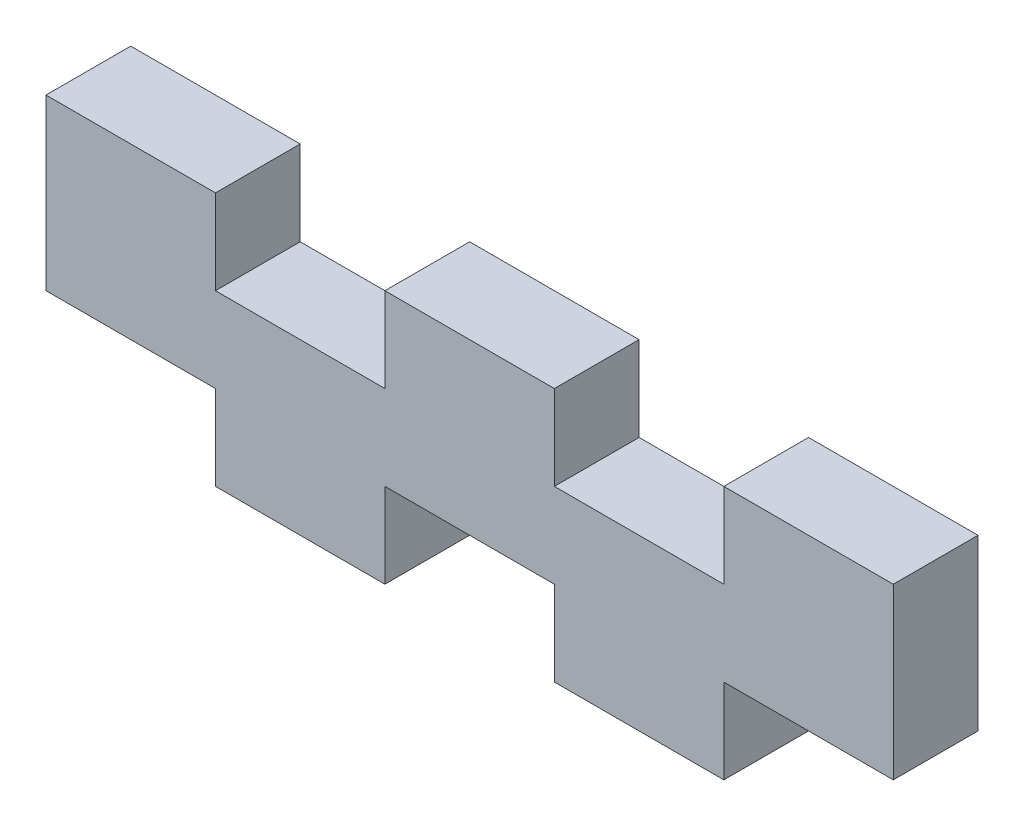
from build123d import *

# Parameters (mm, degrees)
SKETCH1_W           = 50.8
SKETCH1_H           = 15.24
BOSS_EXTRUDE1_DEPTH = 5.08
CUT_EXTRUDE2_REACH  = 7.08
SKETCH3_W           = 10.16
SKETCH3_H           = 5.08
CUT_EXTRUDE3_REACH  = 7.08
SKETCH4_W           = 10.16
SKETCH4_H           = 5.08


with BuildPart() as part:
    # Sketch1 → Boss-Extrude1 (new body)
    with BuildSketch(Plane.XY):
        with Locations((25.4, 7.62)):
            Rectangle(SKETCH1_W, SKETCH1_H)
    extrude(amount=BOSS_EXTRUDE1_DEPTH)

    # Sketch3 → Cut-Extrude2 (cut, up to next)
    with BuildSketch(Plane(origin=(0, 0, 0), x_dir=(-1, 0, 0), z_dir=(0, 0, -1)), mode=Mode.PRIVATE) as cut_extrude2_sk1:
        with Locations((-5.08, 2.54)):
            Rectangle(SKETCH3_W, SKETCH3_H)
    cut_extrude2_tool1 = extrude(cut_extrude2_sk1.sketch, amount=-CUT_EXTRUDE2_REACH, mode=Mode.PRIVATE) & part.part
    add(cut_extrude2_tool1.solids().sort_by_distance((5.08, 2.54, 0))[0], mode=Mode.SUBTRACT)
    # Sketch3 → Cut-Extrude2 (cut, up to next)
    with BuildSketch(Plane(origin=(0, 0, 0), x_dir=(-1, 0, 0), z_dir=(0, 0, -1)), mode=Mode.PRIVATE) as cut_extrude2_sk2:
        with Locations((-25.4, 2.54)):
            Rectangle(SKETCH3_W, SKETCH3_H)
    cut_extrude2_tool2 = extrude(cut_extrude2_sk2.sketch, amount=-CUT_EXTRUDE2_REACH, mode=Mode.PRIVATE) & part.part
    add(cut_extrude2_tool2.solids().sort_by_distance((25.4, 2.54, 0))[0], mode=Mode.SUBTRACT)
    # Sketch3 → Cut-Extrude2 (cut, up to next)
    with BuildSketch(Plane(origin=(0, 0, 0), x_dir=(-1, 0, 0), z_dir=(0, 0, -1)), mode=Mode.PRIVATE) as cut_extrude2_sk3:
        with Locations((-45.72, 2.54)):
            Rectangle(SKETCH3_W, SKETCH3_H)
    cut_extrude2_tool3 = extrude(cut_extrude2_sk3.sketch, amount=-CUT_EXTRUDE2_REACH, mode=Mode.PRIVATE) & part.part
    add(cut_extrude2_tool3.solids().sort_by_distance((45.72, 2.54, 0))[0], mode=Mode.SUBTRACT)

    # Sketch4 → Cut-Extrude3 (cut, up to next)
    with BuildSketch(Plane.XY.offset(5.08), mode=Mode.PRIVATE) as cut_extrude3_sk1:
        with Locations((15.24, 12.7)):
            Rectangle(SKETCH4_W, SKETCH4_H)
    cut_extrude3_tool1 = extrude(cut_extrude3_sk1.sketch, amount=-CUT_EXTRUDE3_REACH, mode=Mode.PRIVATE) & part.part
    add(cut_extrude3_tool1.solids().sort_by_distance((15.24, 12.7, 5.08))[0], mode=Mode.SUBTRACT)
    # Sketch4 → Cut-Extrude3 (cut, up to next)
    with BuildSketch(Plane.XY.offset(5.08), mode=Mode.PRIVATE) as cut_extrude3_sk2:
        with Locations((35.56, 12.7)):
            Rectangle(SKETCH4_W, SKETCH4_H)
    cut_extrude3_tool2 = extrude(cut_extrude3_sk2.sketch, amount=-CUT_EXTRUDE3_REACH, mode=Mode.PRIVATE) & part.part
    add(cut_extrude3_tool2.solids().sort_by_distance((35.56, 12.7, 5.08))[0], mode=Mode.SUBTRACT)


solid = part.part
